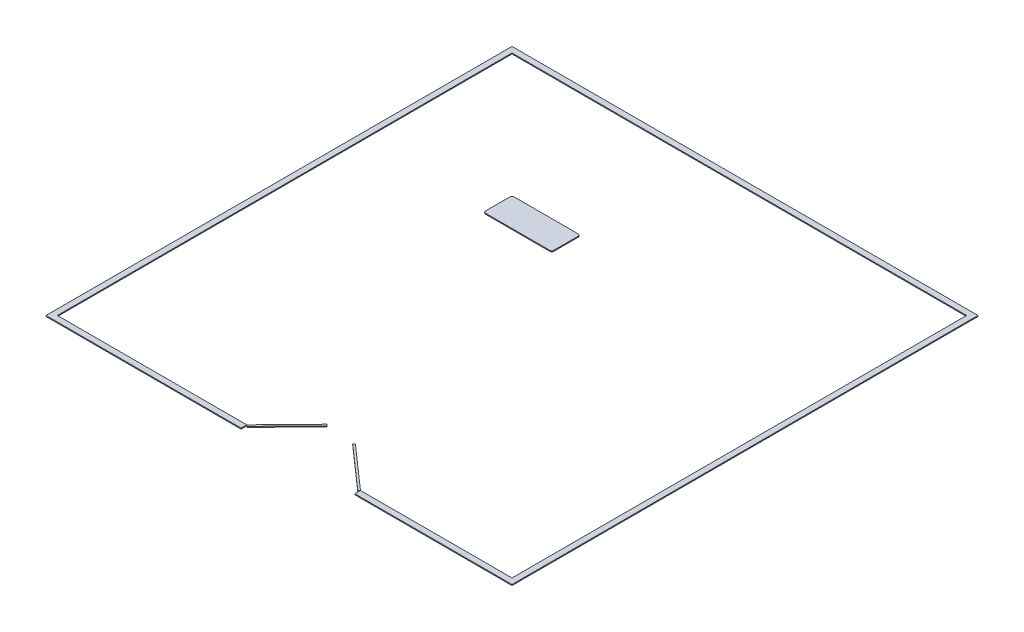
from build123d import *

# Parameters (mm, degrees)
SKETCH1_W           = 12496.8
SKETCH1_H           = 12496.8
SKETCH1_W_2         = 12192
SKETCH1_H_2         = 12192
OUTSIDE_PERIM_DEPTH = 25.4
SKETCH2_W           = 3048
SKETCH2_H           = 152.4
DOORWAY_DEPTH       = 26.4
TABLE_DEPTH         = 25.4
DOORS_DEPTH         = 25.4
DOORS_2_DEPTH       = 25.4


with BuildPart() as part:
    # Sketch1 → Outside_Perim (new body)
    with BuildSketch(Plane(origin=(0, 0, 0), x_dir=(1, 0, 0), z_dir=(0, 1, 0))):
        with Locations((6096, 6096)):
            Rectangle(SKETCH1_W, SKETCH1_H)
        with Locations((6096, 6096)):
            Rectangle(SKETCH1_W_2, SKETCH1_H_2, mode=Mode.SUBTRACT)
    extrude(amount=OUTSIDE_PERIM_DEPTH)

    # Sketch2 → Doorway (cut, through all)
    with BuildSketch(Plane(origin=(0, 25.4, 0), x_dir=(1, 0, 0), z_dir=(0, 1, 0))):
        with Locations((6604, -76.2)):
            Rectangle(SKETCH2_W, SKETCH2_H)
    extrude(amount=-DOORWAY_DEPTH, mode=Mode.SUBTRACT)


with BuildPart() as body_2:
    # Sketch3 → Table (new body)
    with BuildSketch(Plane(origin=(0, 0, 0), x_dir=(1, 0, 0), z_dir=(0, 1, 0))):
        with BuildLine():
            Line((3365.055060067, 8877.659504367), (5092.255060067, 8877.659504367))
            ThreePointArc((5092.255060067, 8877.659504367), (5128.176084551, 8862.780528852), (5143.055060067, 8826.859504367))
            Line((5143.055060067, 8826.859504367), (5143.055060067, 8166.459504367))
            ThreePointArc((5143.055060067, 8166.459504367), (5128.176084551, 8130.538479883), (5092.255060067, 8115.659504367))
            Line((5092.255060067, 8115.659504367), (3365.055060067, 8115.659504367))
            ThreePointArc((3365.055060067, 8115.659504367), (3329.134035583, 8130.538479883), (3314.255060067, 8166.459504367))
            Line((3314.255060067, 8166.459504367), (3314.255060067, 8826.859504367))
            ThreePointArc((3314.255060067, 8826.859504367), (3329.134035583, 8862.780528852), (3365.055060067, 8877.659504367))
        make_face()
    extrude(amount=TABLE_DEPTH)


with BuildPart() as body_3:
    # Sketch4 → Doors (new body)
    with BuildSketch(Plane(origin=(0, 0, 0), x_dir=(1, 0, 0), z_dir=(0, 1, 0))):
        Polygon((5080, 0), (6143.356590999, 1091.718260532), (6179.747199683, 1056.273040832), (5116.390608684, -35.4452197), align=None)
    extrude(amount=DOORS_DEPTH)


with BuildPart() as body_4:
    # Sketch4 → Doors 2 (new body)
    with BuildSketch(Plane(origin=(0, 0, 0), x_dir=(1, 0, 0), z_dir=(0, 1, 0))):
        Polygon((8128, 0), (6984.857103754, 1007.869197248), (6951.261463845, 969.76443404), (8091.387859263, -35.4452197), align=None)
    extrude(amount=DOORS_2_DEPTH)


solid = Compound([part.part, body_2.part, body_3.part, body_4.part])
